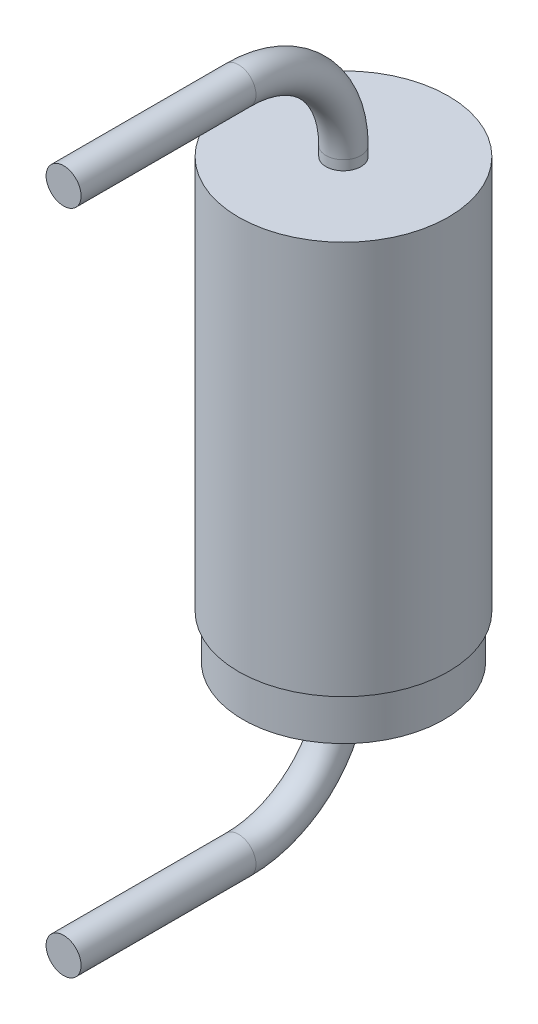
from build123d import *

# Parameters (mm, degrees)
BOSS_EXTRUDE1_DEPTH      = 2.5
BOSS_EXTRUDE1_DEPTH_BACK = 2.5
SKETCH2_R                = 1.2
SWEEP1_PROFILE_R         = 0.2
SKETCH23_R               = 1.2
SKETCH23_R_2             = 1.15
CUT_EXTRUDE1_DEPTH       = 0.5


with BuildPart() as part:
    # Sketch2 → Boss-Extrude1 (new, two sides: drawn at the far end of the back side and taken through both)
    with BuildSketch(Plane(origin=(0, 0, 0), x_dir=(1, 0, 0), z_dir=(0, 1, 0)).offset(-BOSS_EXTRUDE1_DEPTH_BACK)):
        Circle(SKETCH2_R)
    extrude(amount=BOSS_EXTRUDE1_DEPTH + BOSS_EXTRUDE1_DEPTH_BACK)

    # Sweep1: sweep along a path in Sketch3
    with BuildLine(Plane(origin=(0, 0, 0), x_dir=(0, 0, -1), z_dir=(1, 0, 0))) as sweep1_path:
        Line((0, 2.5), (0, 2.61))
        ThreePointArc((0, 2.61), (-0.351471863, 3.458528137), (-1.2, 3.81))
        Line((-1.2, 3.81), (-3.2, 3.81))
    # Sweep1 profile (on start of the path) → Sweep1 (sweep)
    with BuildSketch(Plane.ZX.offset(2.5)):
        Circle(SWEEP1_PROFILE_R)
    sweep1 = sweep(path=sweep1_path.line)

    # Mirror1: Sweep1 across plane
    add(sweep1.mirror(Plane.ZX))

    # Sketch23 → Cut-Extrude1 (cut)
    with BuildSketch(Plane.XZ.offset(2.5)):
        Circle(SKETCH23_R)
        Circle(SKETCH23_R_2, mode=Mode.SUBTRACT)
    extrude(amount=-CUT_EXTRUDE1_DEPTH, mode=Mode.SUBTRACT)


solid = part.part
